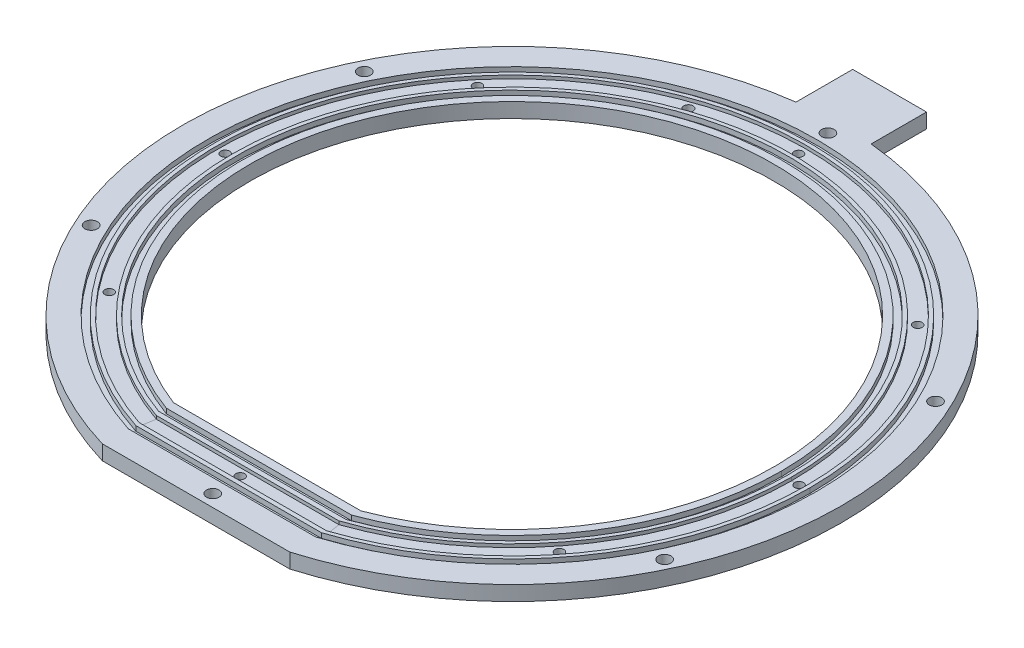
from build123d import *

# Parameters (mm, degrees)
BOSS_EXTRUDE2_DEPTH  = 4
CUT_EXTRUDE2_DEPTH   = 4
SKETCH67_W           = 1.78
SKETCH67_H           = 1.335
M3_CLEARANCE_HOLE1_D = 3.4
M3_CLEARANCE_HOLE2_D = 3.4
M3_CLEARANCE_HOLE3_D = 3.4
SKETCH85_R           = 1.25
CUT_EXTRUDE3_DEPTH   = 3.5
SKETCH88_W           = 4
SKETCH88_H           = 0.89
SKETCH89_W           = 1.78
SKETCH89_H           = 1.335
M2_CLEARANCE_HOLE1_D = 2.4


with BuildPart() as part:
    # Sketch1 → Boss-Extrude2 (new body)
    with BuildSketch(Plane(origin=(0, 0, 0), x_dir=(1, 0, 0), z_dir=(0, 1, 0))):
        with BuildLine():
            Line((8.406024478, 88.883390757), (8.406024478, 103.883390757))
            Line((8.406024478, 103.883390757), (-11.593975522, 103.883390757))
            Line((-11.593975522, 103.883390757), (-11.593975522, 88.52399749))
            ThreePointArc((-11.593975522, 88.52399749), (-89.000649896, 7.05710409), (-25.4, -85.590644349))
            Line((-25.4, -85.590644349), (25.4, -85.590644349))
            ThreePointArc((25.4, -85.590644349), (88.859490513, 8.655018529), (8.406024478, 88.883390757))
        make_face()
    extrude(amount=BOSS_EXTRUDE2_DEPTH)

    # Sketch65 → Cut-Extrude2 (cut)
    with BuildSketch(Plane(origin=(0, 4, 0), x_dir=(1, 0, 0), z_dir=(0, 1, 0))):
        with BuildLine():
            Line((-25.4, -66.301131212), (25.4, -66.301131212))
            ThreePointArc((25.4, -66.301131212), (0, 71), (-25.4, -66.301131212))
        make_face()
    extrude(amount=-CUT_EXTRUDE2_DEPTH, mode=Mode.SUBTRACT)

    # Cut-Sweep4: sweep along a path in Sketch66
    with BuildLine(Plane(origin=(0, 4, 0), x_dir=(1, 0, 0), z_dir=(0, 1, 0))) as cut_sweep4_path:
        Line((-25.4, -70.334119743), (25.4, -70.334119743))
        ThreePointArc((25.4, -70.334119743), (0, 74.78), (-25.4, -70.334119743))
    # Sketch67 → Cut-Sweep4 (sweep, cut)
    with BuildSketch(Plane.XY):
        with Locations((73.89, 3.3325)):
            Rectangle(SKETCH67_W, SKETCH67_H)
    sweep(path=cut_sweep4_path.line, transition=Transition.RIGHT, mode=Mode.SUBTRACT)

    # M3 Clearance Hole1 (through all)
    with Locations(Plane(origin=(0, 4, 0), x_dir=(1, 0, 0), z_dir=(0, 1, 0))):
        with Locations((0, 85.579948689), (1.258033759, -82.305617091)):
            Hole(M3_CLEARANCE_HOLE1_D / 2)

    # M3 Clearance Hole2 (through all)
    with Locations(Plane(origin=(0, 4, 0), x_dir=(1, 0, 0), z_dir=(0, 1, 0))):
        with Locations((77.517333543, 37.213824549), (-77.23229895, 37.213824549), (77.918774008, -36.561345364)):
            Hole(M3_CLEARANCE_HOLE2_D / 2)

    # M3 Clearance Hole3 (through all)
    with Locations(Plane(origin=(0, 4, 0), x_dir=(1, 0, 0), z_dir=(0, 1, 0))):
        with Locations((-78.180925209, -35.838567256)):
            Hole(M3_CLEARANCE_HOLE3_D / 2)

    # Sketch85 → Cut-Extrude3 (cut)
    with BuildSketch(Plane(origin=(0, 0, 0), x_dir=(1, 0, 0), z_dir=(0, 1, 0))):
        with Locations((-25.56306074, 73.350248883)):
            Circle(SKETCH85_R)
    extrude(amount=CUT_EXTRUDE3_DEPTH, mode=Mode.SUBTRACT)

    # Cut-Sweep6: sweep along a path in Sketch86
    with BuildLine(Plane(origin=(0, 4, 0), x_dir=(1, 0, 0), z_dir=(0, 1, 0))) as cut_sweep6_path:
        Line((-25.4, -75.628621566), (25.4, -75.628621566))
        ThreePointArc((25.4, -75.628621566), (0, 79.78), (-25.4, -75.628621566))
    # Sketch88 → Cut-Sweep6 (sweep, cut)
    with BuildSketch(Plane.XY):
        with Locations((77.78, 3.555)):
            Rectangle(SKETCH88_W, SKETCH88_H)
    sweep(path=cut_sweep6_path.line, transition=Transition.RIGHT, mode=Mode.SUBTRACT)

    # Cut-Sweep7: sweep along a path in Sketch70
    with BuildLine(Plane(origin=(0, 4, 0), x_dir=(1, 0, 0), z_dir=(0, 1, 0))) as cut_sweep7_path:
        Line((-25.4, -78.555671979), (25.4, -78.555671979))
        ThreePointArc((25.4, -78.555671979), (0, 82.56), (-25.4, -78.555671979))
    # Sketch89 → Cut-Sweep7 (sweep, cut)
    with BuildSketch(Plane.XY):
        with Locations((81.67, 3.3325)):
            Rectangle(SKETCH89_W, SKETCH89_H)
    sweep(path=cut_sweep7_path.line, transition=Transition.RIGHT, mode=Mode.SUBTRACT)

    # M2 Clearance Hole1 (through all)
    with Locations(Plane(origin=(0, 3.11, 0), x_dir=(1, 0, 0), z_dir=(0, 1, 0))):
        with Locations((0, 77.631751955), (0, -73.630259495), (77.78, 0), (-77.704091358, 0), (56.271914446, 53.625280977), (-59.401726527, 50.055397688), (61.027015564, -48.167486171), (-60.932251647, -48.167486171)):
            Hole(M2_CLEARANCE_HOLE1_D / 2)


solid = part.part
